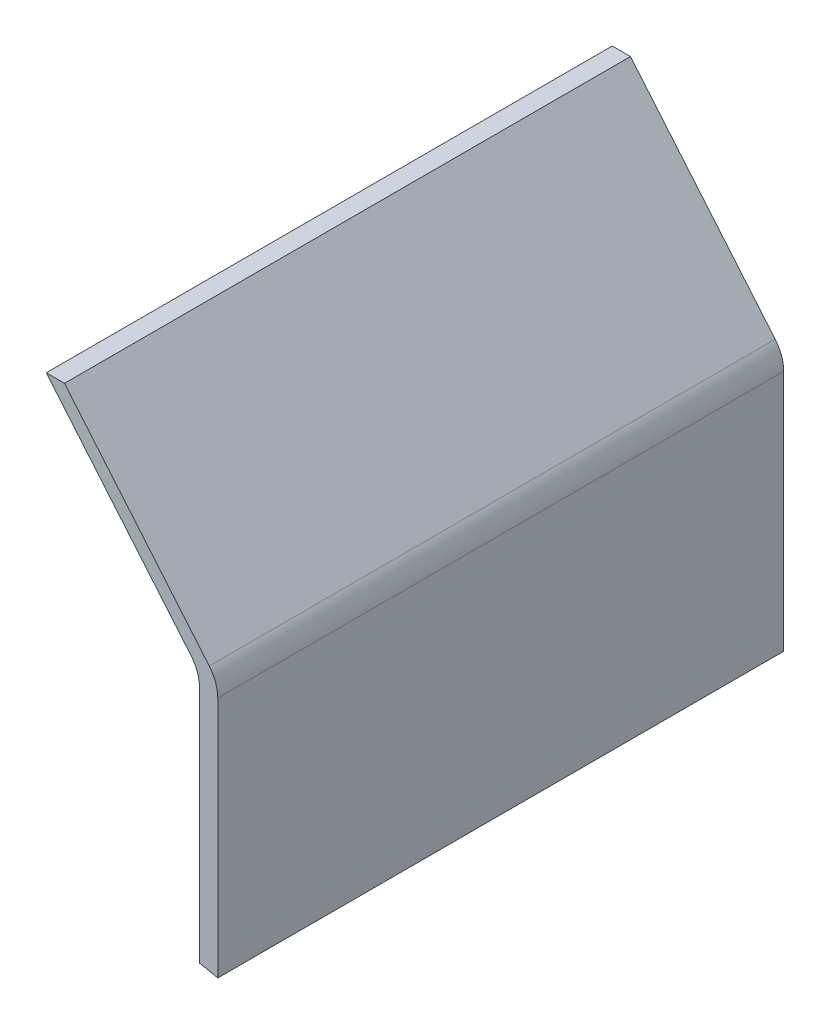
from build123d import *

# Parameters (mm, degrees)
FUNNEL_LEFT_SIDE_DEPTH = 155
FILLET1_R              = 10


with BuildPart() as part:
    # Sketch1 → Funnel - Left Side (new body)
    with BuildSketch(Plane.XY):
        with BuildLine():
            Line((-5, 1.037386495), (-5, 70.037386495))
            Line((-5, 70.037386495), (-46.974030913, 120.060088631))
            Line((-46.974030913, 120.060088631), (-41.974030913, 120.060088631))
            Line((-41.974030913, 120.060088631), (0, 70.037386495))
            Line((0, 70.037386495), (0, 0))
            ThreePointArc((0, 0), (-2.495861145, 0.538641718), (-5, 1.037386495))
        make_face()
    extrude(amount=FUNNEL_LEFT_SIDE_DEPTH)

    # Fillet1
    fillet1_edges = [part.edges().sort_by_distance(p)[0] for p in [
        (-5, 70.037386495, 77.5),
        (0, 70.037386495, 77.5),
    ]]
    fillet(fillet1_edges, radius=FILLET1_R)


solid = part.part
